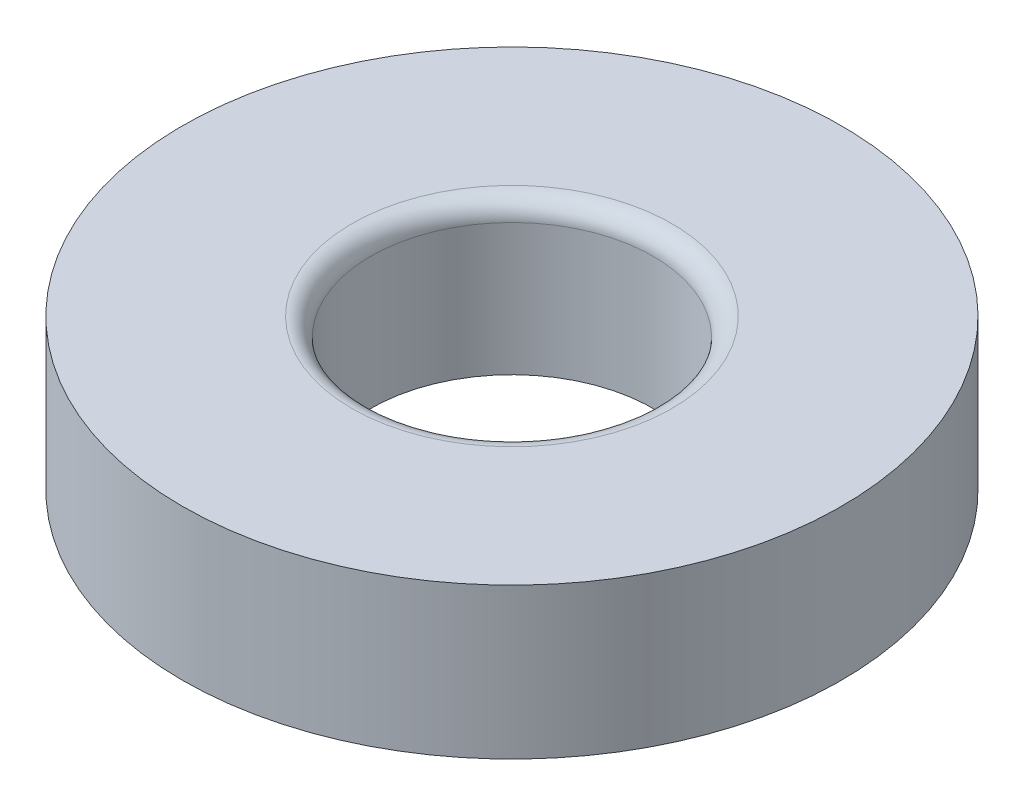
from build123d import *

# Parameters (mm, degrees)
SKETCH1_R           = 17.5
BOSS_EXTRUDE1_DEPTH = 8
SKETCH2_R           = 7.5
CUT_EXTRUDE1_DEPTH  = 9
FILLET1_R           = 1


with BuildPart() as part:
    # Sketch1 → Boss-Extrude1 (new body)
    with BuildSketch(Plane(origin=(0, 0, 0), x_dir=(1, 0, 0), z_dir=(0, 1, 0))):
        Circle(SKETCH1_R)
    extrude(amount=BOSS_EXTRUDE1_DEPTH)

    # Sketch2 → Cut-Extrude1 (cut, through all)
    with BuildSketch(Plane(origin=(0, 8, 0), x_dir=(1, 0, 0), z_dir=(0, 1, 0))):
        Circle(SKETCH2_R)
    extrude(amount=-CUT_EXTRUDE1_DEPTH, mode=Mode.SUBTRACT)

    # Fillet1
    fillet1_edges = [part.edges().sort_by_distance(p)[0] for p in [
        (-7.5, 8, 0),
    ]]
    fillet(fillet1_edges, radius=FILLET1_R)


solid = part.part
